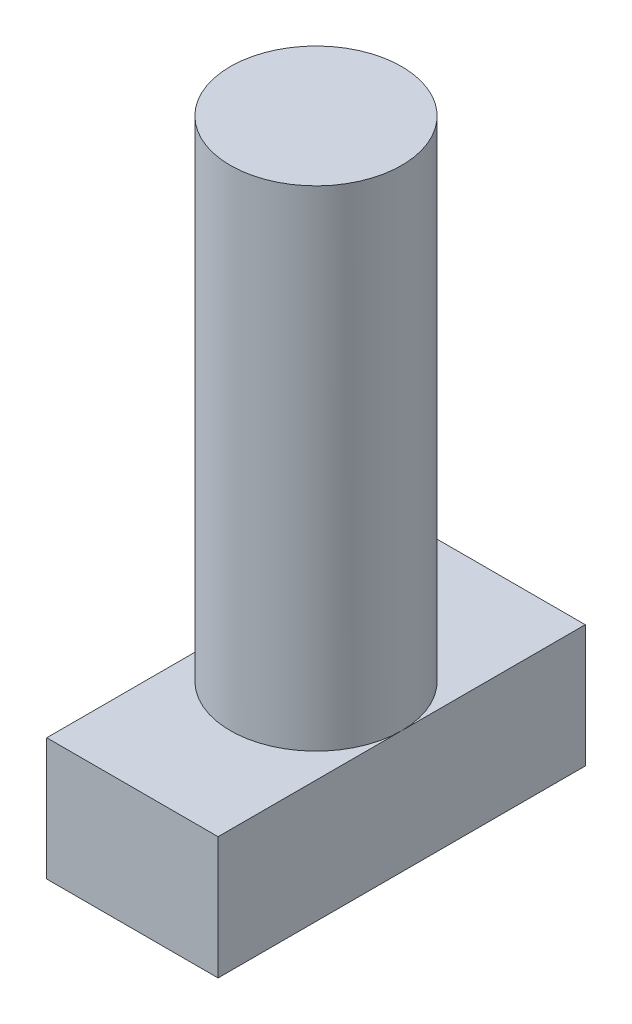
from build123d import *

# Parameters (mm, degrees)
SKETCH1_W           = 14
SKETCH1_H           = 30
BOSS_EXTRUDE1_DEPTH = 10
SKETCH2_R           = 7
BOSS_EXTRUDE2_DEPTH = 40


with BuildPart() as part:
    # Sketch1 → Boss-Extrude1 (new body)
    with BuildSketch(Plane(origin=(0, 0, 0), x_dir=(1, 0, 0), z_dir=(0, 1, 0))):
        Rectangle(SKETCH1_W, SKETCH1_H)
    extrude(amount=BOSS_EXTRUDE1_DEPTH)

    # Sketch2 → Boss-Extrude2 (add)
    with BuildSketch(Plane(origin=(0, 10, 0), x_dir=(1, 0, 0), z_dir=(0, 1, 0))):
        Circle(SKETCH2_R)
    extrude(amount=BOSS_EXTRUDE2_DEPTH)


solid = part.part
